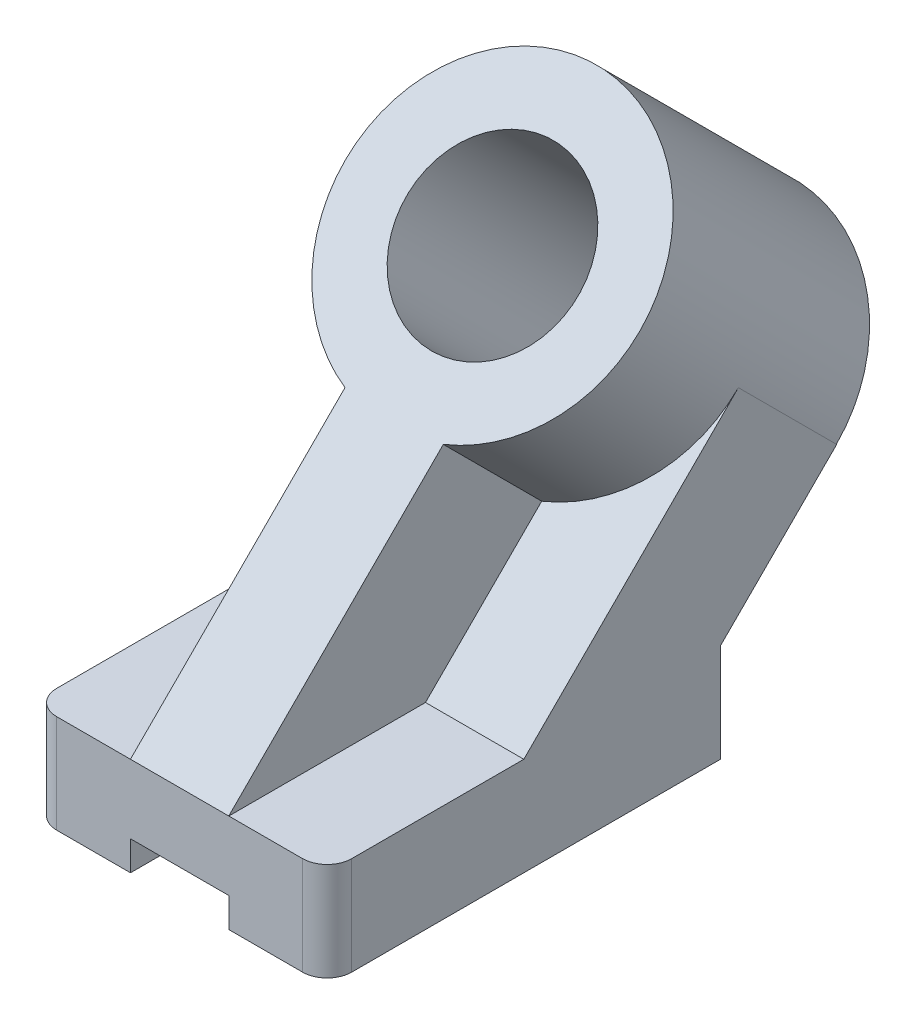
from build123d import *

# Parameters (mm, degrees)
SKETCH1_W                = 76.2
SKETCH1_H                = 25.4
BOSS_EXTRUDE1_DEPTH      = 101.6
BOSS_EXTRUDE2_DEPTH      = 76.2
BOSS_EXTRUDE3_DEPTH      = 35.941
BOSS_EXTRUDE3_DEPTH_BACK = 35.814
SKETCH5_R                = 22.225
CUT_EXTRUDE1_DEPTH       = 148.955
CUT_EXTRUDE2_DEPTH       = 51.724322261
CUT_EXTRUDE3_DEPTH       = 159.487395714


with BuildPart() as part:
    # Sketch1 → Boss-Extrude1 (new body)
    with BuildSketch(Plane.XY):
        with Locations((-8.908273381, -11.00971223)):
            Rectangle(SKETCH1_W, SKETCH1_H)
    extrude(amount=-BOSS_EXTRUDE1_DEPTH)

    # Sketch3 → Boss-Extrude2 (add, through all)
    with BuildSketch(Plane(origin=(29.191726619, 0, 0), x_dir=(0, 0, -1), z_dir=(1, 0, 0))):
        Polygon((50.8, 1.69028777), (106.22230509, 57.112592859), (131.62230509, 31.712592859), (101.6, 1.69028777), align=None)
    extrude(amount=-BOSS_EXTRUDE2_DEPTH)

    # Sketch4 → Boss-Extrude3 (add, two sides)
    with BuildSketch(Plane(origin=(0, -24.554856115, -24.554856115), x_dir=(1, 0, 0), z_dir=(0, 0.707106781, 0.707106781))) as boss_extrude3_sk:
        with BuildLine():
            Line((-21.608273381, 1.195213944), (3.791726619, 1.195213944))
            Line((3.791726619, 1.195213944), (3.791726619, 79.57418946))
            ThreePointArc((3.791726619, 79.57418946), (-8.908273381, 153.595213944), (-21.608273381, 79.57418946))
            Line((-21.608273381, 79.57418946), (-21.608273381, 1.195213944))
        make_face()
    extrude(amount=BOSS_EXTRUDE3_DEPTH)
    extrude(boss_extrude3_sk.sketch, amount=-BOSS_EXTRUDE3_DEPTH_BACK)

    # Sketch5 → Cut-Extrude1 (cut, through all)
    with BuildSketch(Plane(origin=(0, 0.859268708, 0.859268708), x_dir=(1, 0, 0), z_dir=(0, 0.707106781, 0.707106781))):
        with Locations((-8.908273381, 115.495213944)):
            Circle(SKETCH5_R)
    extrude(amount=-CUT_EXTRUDE1_DEPTH, mode=Mode.SUBTRACT)

    # Sketch6 → Cut-Extrude2 (cut, through all)
    with BuildSketch(Plane(origin=(0, 1.69028777, 0), x_dir=(1, 0, 0), z_dir=(0, 1, 0))):
        with BuildLine():
            Line((-47.008273381, 6.35), (-47.008273381, 0))
            Line((-47.008273381, 0), (-40.658273381, 0))
            ThreePointArc((-40.658273381, 0), (-45.148401442, 1.859871939), (-47.008273381, 6.35))
        make_face()
        with BuildLine():
            Line((22.841726619, 0), (29.191726619, 0))
            Line((29.191726619, 0), (29.191726619, 6.35))
            ThreePointArc((29.191726619, 6.35), (27.331854679, 1.859871939), (22.841726619, 0))
        make_face()
    extrude(amount=-CUT_EXTRUDE2_DEPTH, mode=Mode.SUBTRACT)

    # Sketch7 → Cut-Extrude3 (cut, through all)
    with BuildSketch(Plane.XY):
        Polygon((-21.608273381, -23.70971223), (-21.608273381, -16.08971223), (3.791726619, -16.08971223), (3.791726619, -23.70971223), (3.791726619, -49.034034492), (-21.608273381, -49.034034492), align=None)
    extrude(amount=-CUT_EXTRUDE3_DEPTH, mode=Mode.SUBTRACT)


solid = part.part
